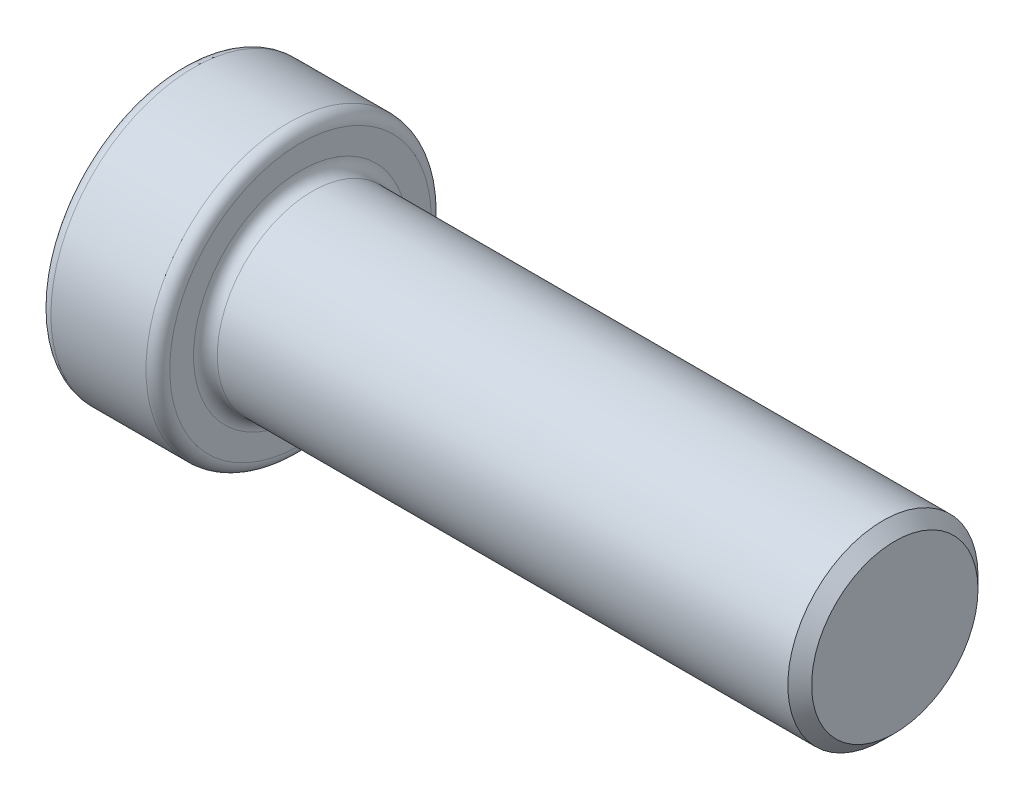
from build123d import *

# Parameters (mm, degrees)
CHAFL_N1_SIZE = 0.5
REDONDEO1_R   = 0.5


with BuildPart() as part:
    # Croquis1 → Revolución1 (revolve)
    with BuildSketch(Plane.XY):
        Polygon((0, 0), (0, 4), (-25, 4), (-25, 6), (-30, 6), (-30, 2.5), (-5, 2.5), (-5, 0), align=None)
    revolve(axis=Axis((0, 0, 0), (-1, 0, 0)))

    # Chaflán1
    chafl_n1_edges = [part.edges().sort_by_distance(p)[0] for p in [
        (-30, -2.5, 0),
        (0, -4, 0),
    ]]
    chamfer(chafl_n1_edges, length=CHAFL_N1_SIZE)

    # Redondeo1
    redondeo1_edges = [part.edges().sort_by_distance(p)[0] for p in [
        (-30, -6, 0),
        (-25, -6, 0),
        (-25, -4, 0),
    ]]
    fillet(redondeo1_edges, radius=REDONDEO1_R)


solid = part.part
